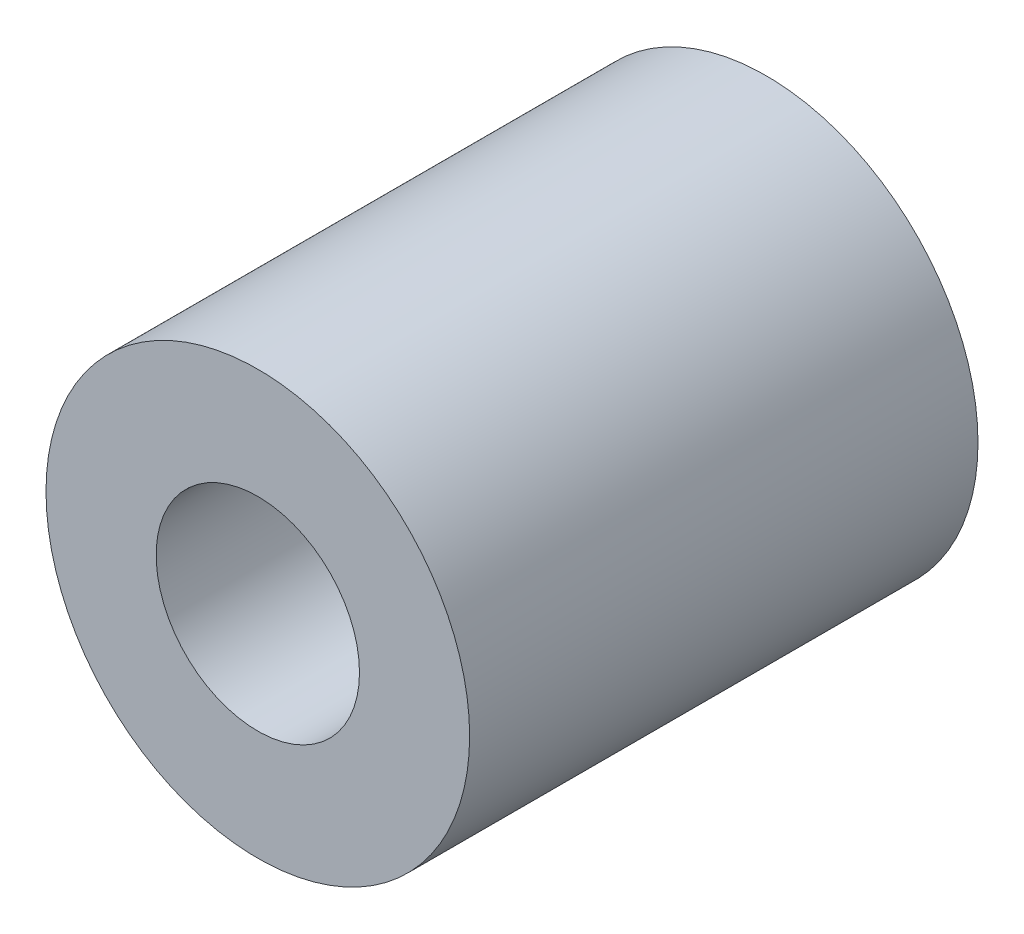
from build123d import *

# Parameters (mm, degrees)
SKETCH1_R           = 12.5
SKETCH1_R_2         = 6
BOSS_EXTRUDE1_DEPTH = 30


with BuildPart() as part:
    # Sketch1 → Boss-Extrude1 (new body)
    with BuildSketch(Plane.XY):
        Circle(SKETCH1_R)
        Circle(SKETCH1_R_2, mode=Mode.SUBTRACT)
    extrude(amount=BOSS_EXTRUDE1_DEPTH)


solid = part.part
